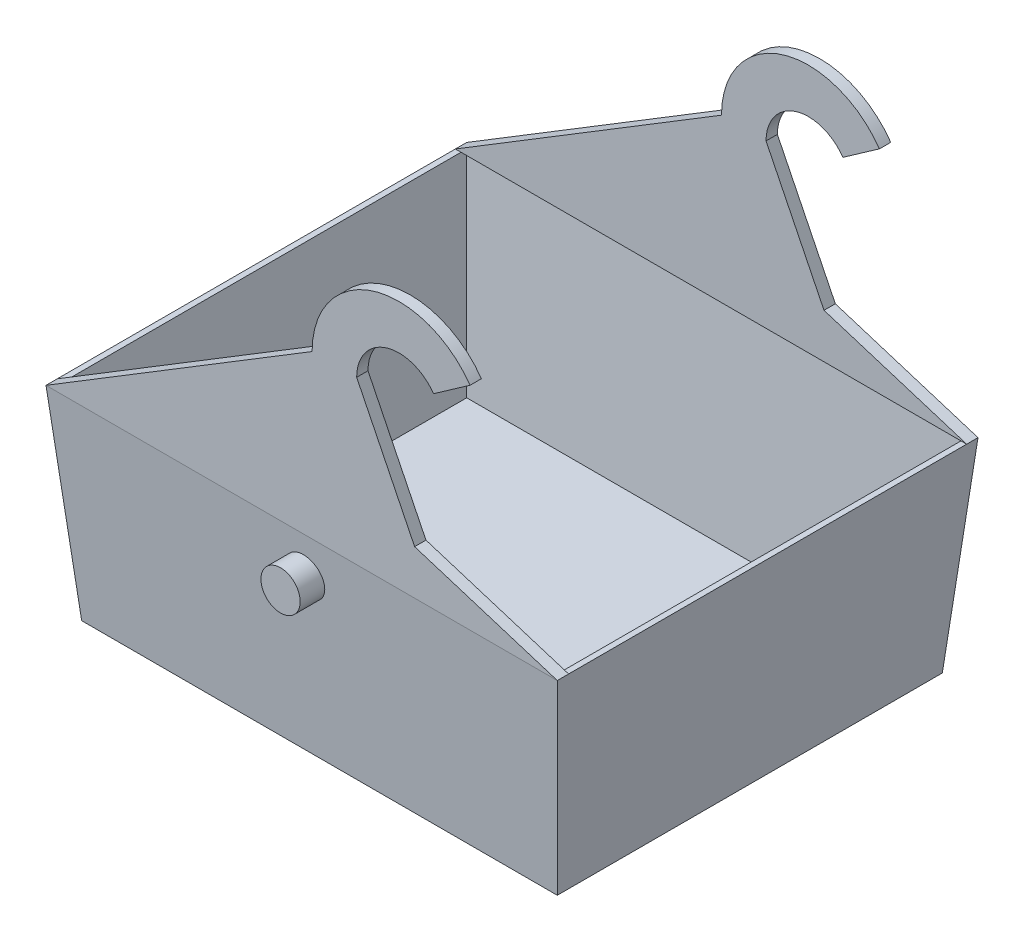
from build123d import *

# Parameters (mm, degrees)
SKETCH1_W           = 266.7
SKETCH1_H           = 215.9
SKETCH1_W_2         = 260.35
SKETCH1_H_2         = 209.55
BOSS_EXTRUDE1_DEPTH = 114.3
BOSS_EXTRUDE1_TAPER = -5
SKETCH1_5_W         = 260.35
SKETCH1_5_H         = 209.55
BOSS_EXTRUDE2_DEPTH = 3.175
BOSS_EXTRUDE2_TAPER = -5
SKETCH3_W           = 280.349908482
SKETCH3_H           = 229.549908482
SKETCH3_W_2         = 240.350091518
SKETCH3_H_2         = 189.550091518
CUT_EXTRUDE1_DEPTH  = 111.125
CUT_EXTRUDE1_TAPER  = 5
BOSS_EXTRUDE3_START = -114.774954
BOSS_EXTRUDE3_DEPTH = 3.175
BOSS_EXTRUDE4_START = -114.774954
SKETCH7_R           = 11
BOSS_EXTRUDE4_DEPTH = 15


with BuildPart() as part:
    # Sketch1 → Boss-Extrude1 (new body)
    with BuildSketch(Plane(origin=(0, 0, 0), x_dir=(1, 0, 0), z_dir=(0, 1, 0))):
        Rectangle(SKETCH1_W, SKETCH1_H)
        Rectangle(SKETCH1_W_2, SKETCH1_H_2, mode=Mode.SUBTRACT)
    extrude(amount=BOSS_EXTRUDE1_DEPTH, taper=BOSS_EXTRUDE1_TAPER)

    # Sketch1_5 → Boss-Extrude2 (add)
    with BuildSketch(Plane(origin=(0, 0, 0), x_dir=(1, 0, 0), z_dir=(0, 1, 0))):
        Rectangle(SKETCH1_5_W, SKETCH1_5_H)
    extrude(amount=BOSS_EXTRUDE2_DEPTH, taper=BOSS_EXTRUDE2_TAPER)

    # Sketch3 → Cut-Extrude1 (cut)
    with BuildSketch(Plane(origin=(0, 114.3, 0), x_dir=(1, 0, 0), z_dir=(0, 1, 0))):
        Rectangle(SKETCH3_W, SKETCH3_H)
        Rectangle(SKETCH3_W_2, SKETCH3_H_2, mode=Mode.SUBTRACT)
    extrude(amount=-CUT_EXTRUDE1_DEPTH, taper=CUT_EXTRUDE1_TAPER, mode=Mode.SUBTRACT)

    # Sketch5 → Boss-Extrude3 (add, symmetric)
    with BuildSketch(Plane.XY.offset(BOSS_EXTRUDE3_START)):
        with BuildLine():
            Line((-143.349954241, 114.3), (5.849954241, 205.3))
            ThreePointArc((5.849954241, 205.3), (39.905581805, 251.746015501), (94.442658798, 233.23317245))
            Line((94.442658798, 233.23317245), (73.963857691, 218.893761542))
            ThreePointArc((73.963857691, 218.893761542), (47.423226793, 227.903091733), (30.849954241, 205.3))
            Line((30.849954241, 205.3), (63.349954241, 139.3))
            Line((63.349954241, 139.3), (143.349954241, 114.3))
            Line((143.349954241, 114.3), (-143.349954241, 114.3))
        make_face()
    boss_extrude3 = extrude(amount=BOSS_EXTRUDE3_DEPTH, both=True)

    # Sketch7 → Boss-Extrude4 (add)
    with BuildSketch(Plane.XY.offset(BOSS_EXTRUDE4_START)):
        with Locations((0, 92.3)):
            Circle(SKETCH7_R)
    boss_extrude4 = extrude(amount=-BOSS_EXTRUDE4_DEPTH)

    # Mirror5: Boss-Extrude3, Boss-Extrude4 across plane
    add(boss_extrude3.mirror(Plane.XY))
    add(boss_extrude4.mirror(Plane.XY))


solid = part.part
